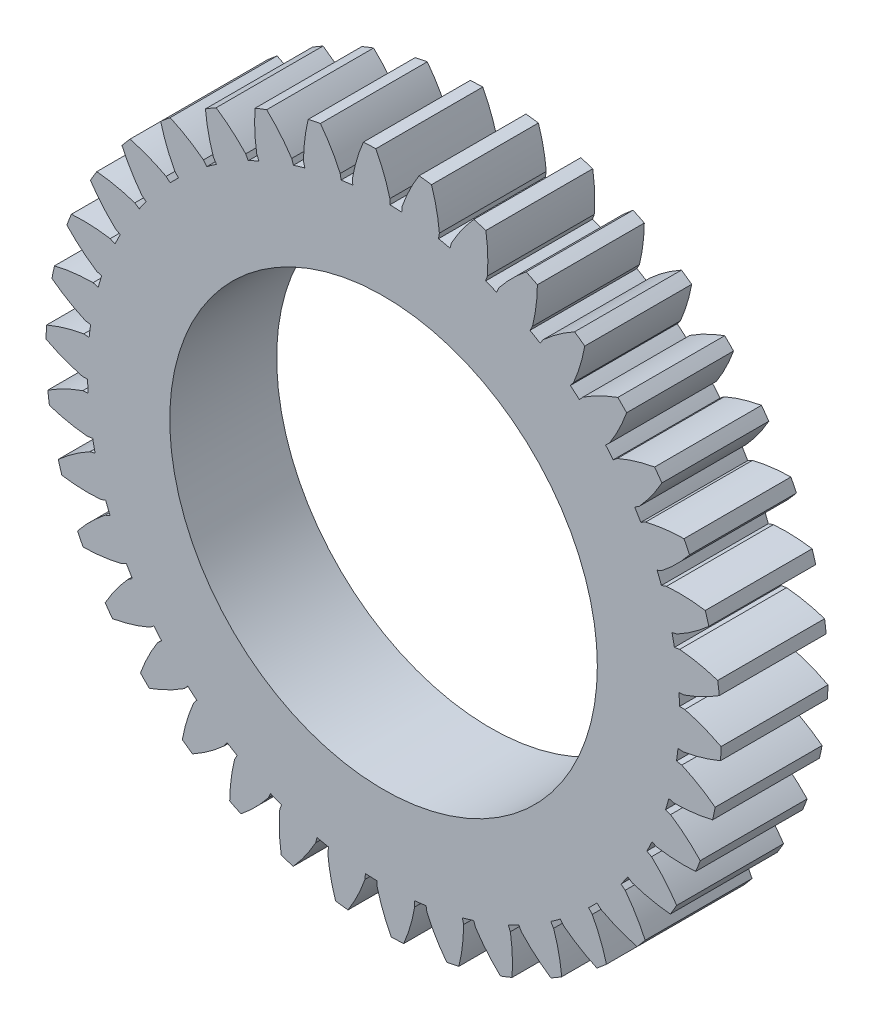
from build123d import *

# Parameters (mm, degrees)
SKETCH2_R           = 35.167288852
BOSS_EXTRUDE1_DEPTH = 12.7
BOSS_EXTRUDE2_DEPTH = 12.7
CIRPATTERN1_COUNT   = 38
SKETCH3_R           = 25.4
CUT_EXTRUDE1_DEPTH  = 12.7


with BuildPart() as part:
    # Sketch2 → Boss-Extrude1 (new body)
    with BuildSketch(Plane.XY):
        Circle(SKETCH2_R)
    extrude(amount=BOSS_EXTRUDE1_DEPTH)

    # Sketch1 → Boss-Extrude2 (add)
    with BuildSketch(Plane.XY):
        with BuildLine():
            Line((0.749813692, 35.159294427), (0.749813692, 35.79443625))
            add(Edge.make_bspline(
                [(-0.914830969, 40.096165002), (-0.195167903, 38.728166625), (0.359713651, 37.294257041), (0.749813692, 35.79443625)],
                knots=[0.127668693, 0.127668693, 0.127668693, 0.127668693, 1, 1, 1, 1], degree=3))
            ThreePointArc((-0.914830969, 40.096165002), (-1.657404212, 40.072339273), (-2.399408705, 40.034762413))
            add(Edge.make_bspline(
                [(-2.399408705, 40.034762413), (-3.003645346, 38.612007139), (-3.438220383, 37.137173328), (-3.703133815, 35.610260979)],
                knots=[0.127668693, 0.127668693, 0.127668693, 0.127668693, 1, 1, 1, 1], degree=3))
            Line((-3.703133815, 35.610260979), (-3.650684219, 34.977288487))
            ThreePointArc((-3.650684219, 34.977288487), (-1.453287306, 35.13724749), (0.749813692, 35.159294427))
        make_face()
    boss_extrude2 = extrude(amount=BOSS_EXTRUDE2_DEPTH)

    # CirPattern1: Boss-Extrude2 ×38 about axis
    cirpattern1_axis = Axis((0, 0, 12.7), (0, 0, 1))
    for i in range(1, CIRPATTERN1_COUNT):
        add(boss_extrude2.rotate(cirpattern1_axis, i * 360 / CIRPATTERN1_COUNT))

    # Sketch3 → Cut-Extrude1 (cut)
    with BuildSketch(Plane.XY.offset(12.7)):
        Circle(SKETCH3_R)
    extrude(amount=-CUT_EXTRUDE1_DEPTH, mode=Mode.SUBTRACT)


solid = part.part
